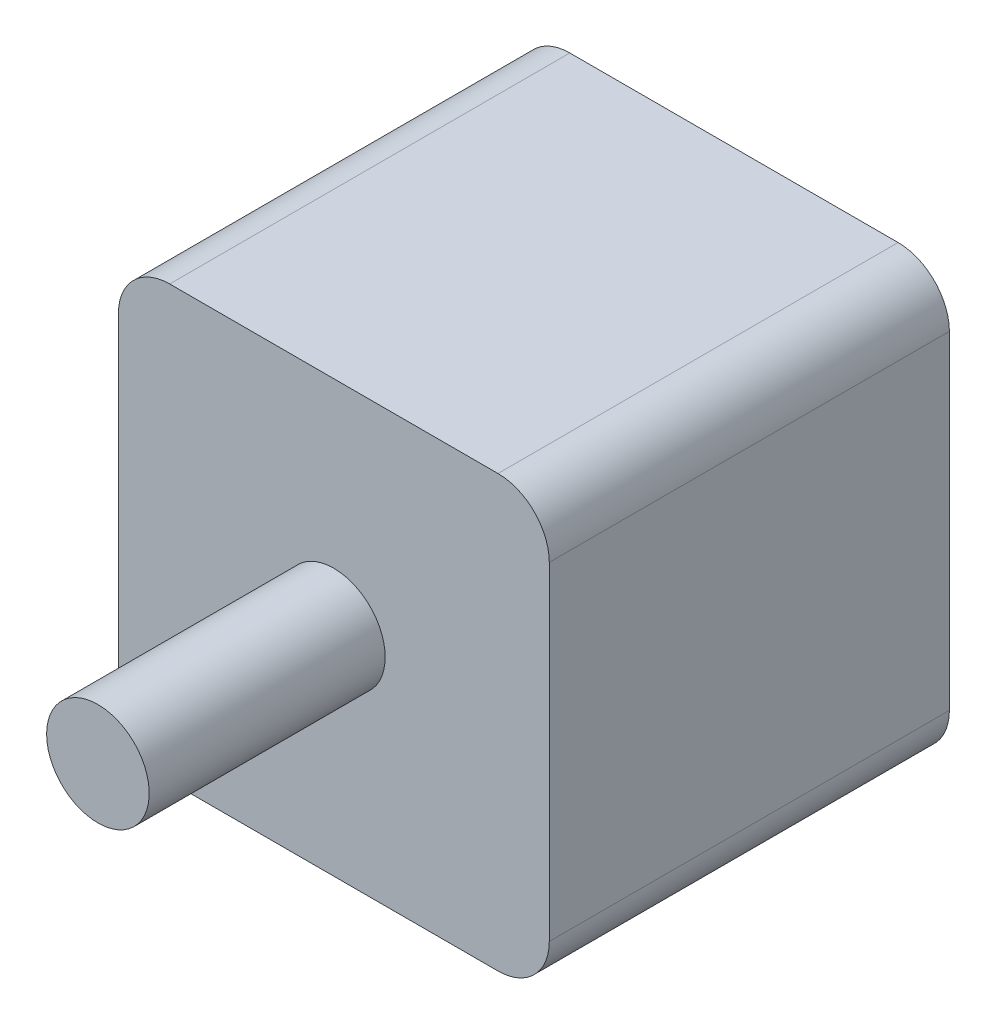
from build123d import *

# Parameters (mm, degrees)
ESQUISSE1_W             = 42
ESQUISSE1_H             = 42
BOSS_EXTRU_1_DEPTH      = 39
CONG_1_R                = 5
ESQUISSE2_R             = 5
BOSS_EXTRU_2_DEPTH      = 23
ESQUISSE3_R             = 5
BOSS_EXTRU_3_DEPTH      = 85
ESQUISSE4_R             = 5
ENL_V_MAT_EXTRU_1_DEPTH = 23


with BuildPart() as part:
    # Esquisse1 → Boss.-Extru.1 (new body)
    with BuildSketch(Plane.XY):
        with Locations((21, -21)):
            Rectangle(ESQUISSE1_W, ESQUISSE1_H)
    extrude(amount=BOSS_EXTRU_1_DEPTH)

    # Congé1
    cong_1_edges = [part.edges().sort_by_distance(p)[0] for p in [
        (0, 0, 19.5),
        (42, 0, 19.5),
        (42, -42, 19.5),
        (0, -42, 19.5),
    ]]
    fillet(cong_1_edges, radius=CONG_1_R)

    # Esquisse2 → Boss.-Extru.2 (add)
    with BuildSketch(Plane(origin=(0, 0, 0), x_dir=(-1, 0, 0), z_dir=(0, 0, -1))):
        with Locations((-21, -21)):
            Circle(ESQUISSE2_R)
    extrude(amount=BOSS_EXTRU_2_DEPTH)

    # Esquisse3 → Boss.-Extru.3 (add)
    with BuildSketch(Plane(origin=(0, 0, -23), x_dir=(-1, 0, 0), z_dir=(0, 0, -1))):
        with Locations((-21, -21)):
            Circle(ESQUISSE3_R)
    extrude(amount=-BOSS_EXTRU_3_DEPTH)

    # Esquisse4 → Enlèv. mat.-Extru.1 (cut)
    with BuildSketch(Plane(origin=(0, 0, -23), x_dir=(-1, 0, 0), z_dir=(0, 0, -1))):
        with Locations((-21, -21)):
            Circle(ESQUISSE4_R)
    extrude(amount=-ENL_V_MAT_EXTRU_1_DEPTH, mode=Mode.SUBTRACT)


solid = part.part
